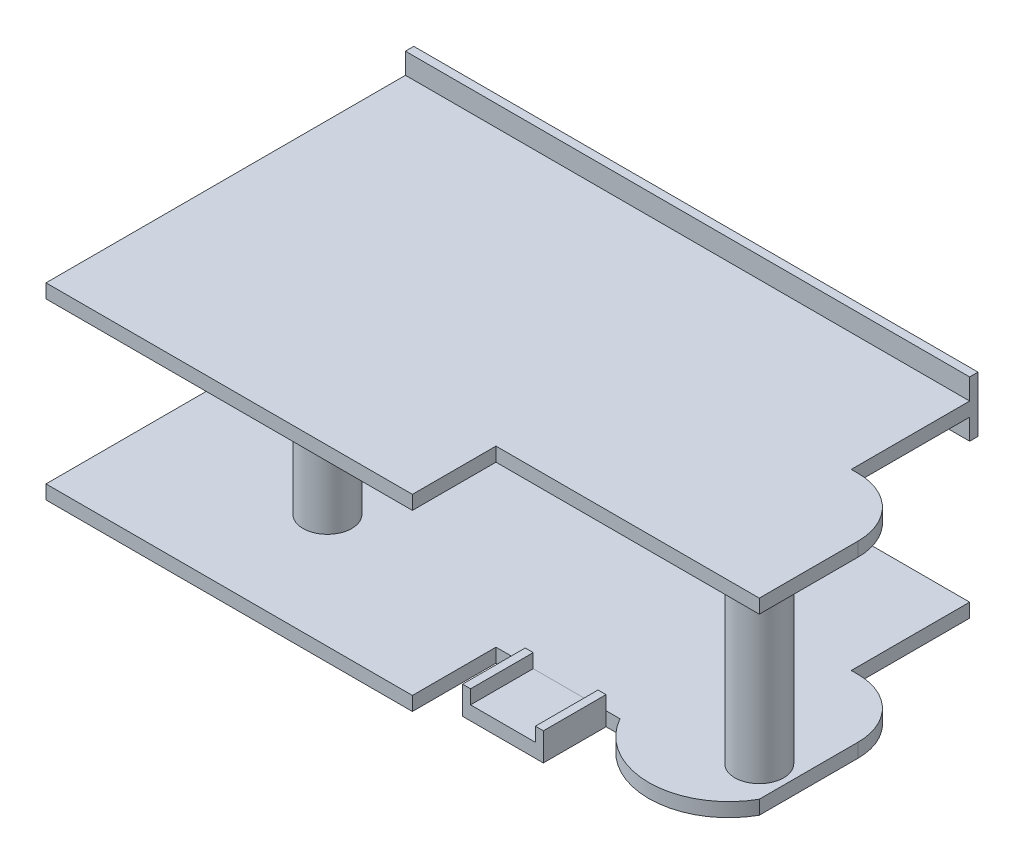
from build123d import *

# Parameters (mm, degrees)
AUFSATZ_LINEAR_AUSTRAGEN0_DEPTH       = 10
SKIZZE1_R                             = 17.5
AUFSATZ_LINEAR_AUSTRAGEN1_DEPTH       = 115
AUFSATZ_LINEAR_AUSTRAGEN2_DEPTH       = 10
VERRUNDUNG1_R                         = 42
AUFSATZ_LINEAR_AUSTRAGEN3_DEPTH       = 10
SKIZZE4_W                             = 405
SKIZZE4_H                             = 40
AUFSATZ_LINEAR_AUSTRAGEN4_DEPTH       = 6
HIER_SOLL_NE_KURVE_DRAUS_WERDEN_DEPTH = 45


with BuildPart() as part:
    # Skizze0 → Aufsatz-Linear austragen0 (new body)
    with BuildSketch(Plane(origin=(0, 0, 0), x_dir=(1, 0, 0), z_dir=(0, 1, 0))):
        Polygon((0, 0), (263, 0), (263, 60), (452, 60), (452, 173), (405, 173), (405, 258), (0, 258), align=None)
    extrude(amount=-AUFSATZ_LINEAR_AUSTRAGEN0_DEPTH)

    # Skizze1 → Aufsatz-Linear austragen1 (add)
    with BuildSketch(Plane(origin=(0, 0, 0), x_dir=(1, 0, 0), z_dir=(0, 1, 0))):
        with Locations(Location((120, 82, 0), (0, 0, 270))):  # turned: the seam where the file's is
            Circle(SKIZZE1_R)
        with Locations(Location((430, 82, 0), (0, 0, 270))):  # turned: the seam where the file's is
            Circle(SKIZZE1_R)
    extrude(amount=AUFSATZ_LINEAR_AUSTRAGEN1_DEPTH)

    # Skizze2 → Aufsatz-Linear austragen2 (add)
    with BuildSketch(Plane(origin=(0, 115, 115), x_dir=(1, 0, 0), z_dir=(0, 1, 0))):
        Polygon((0, 115), (263, 115), (263, 175), (452, 175), (452, 288), (405, 288), (405, 373), (0, 373), align=None)
    extrude(amount=AUFSATZ_LINEAR_AUSTRAGEN2_DEPTH)

    # Verrundung1
    verrundung1_edges = [part.edges().sort_by_distance(p)[0] for p in [
        (452, -5, -173),
        (452, 120, -173),
    ]]
    fillet(verrundung1_edges, radius=VERRUNDUNG1_R)

    # Skizze3 → Aufsatz-Linear austragen3 (add)
    with BuildSketch(Plane(origin=(0, 0, 0), x_dir=(1, 0, 0), z_dir=(0, 1, 0))):
        with BuildLine():
            Line((452, 60), (352, 60))
            ThreePointArc((352, 60), (402, 30.693804872), (452, 60))
        make_face()
    extrude(amount=-AUFSATZ_LINEAR_AUSTRAGEN3_DEPTH)

    # Skizze4 → Aufsatz-Linear austragen4 (add)
    with BuildSketch(Plane(origin=(0, 0, -258), x_dir=(-1, 0, 0), z_dir=(0, 0, -1))):
        with Locations((-202.5, 120)):
            Rectangle(SKIZZE4_W, SKIZZE4_H)
    extrude(amount=AUFSATZ_LINEAR_AUSTRAGEN4_DEPTH)


with BuildPart() as body_2:
    # Profil → Hier soll 'ne Kurve draus werden (new body)
    with BuildSketch(Plane.XY.offset(-60)):
        Polygon((284, 10), (284, -10), (342, -10), (342, 10), (336.25, 10), (336.25, 0), (289.75, 0), (289.75, 10), align=None)
    extrude(amount=HIER_SOLL_NE_KURVE_DRAUS_WERDEN_DEPTH)


solid = Compound([part.part, body_2.part])
